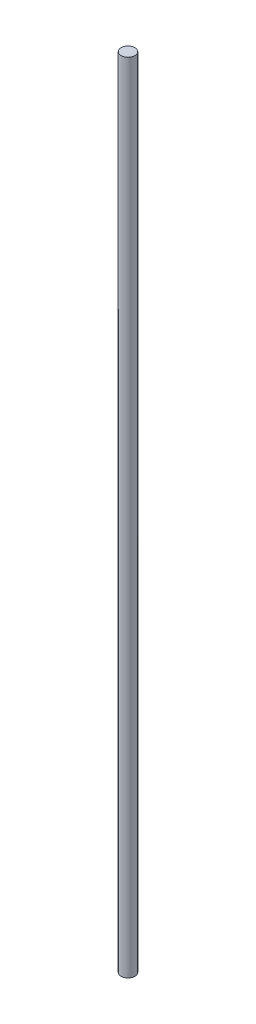
from build123d import *

# Parameters (mm, degrees)
SKETCH2_W = 4.7625
SKETCH2_H = 550


with BuildPart() as part:
    # Sketch2 → Revolve1 (revolve)
    with BuildSketch(Plane.XY):
        with Locations((-2.38125, 275)):
            Rectangle(SKETCH2_W, SKETCH2_H)
    revolve(axis=Axis((0, 0, 0), (0, 1, 0)))


solid = part.part
